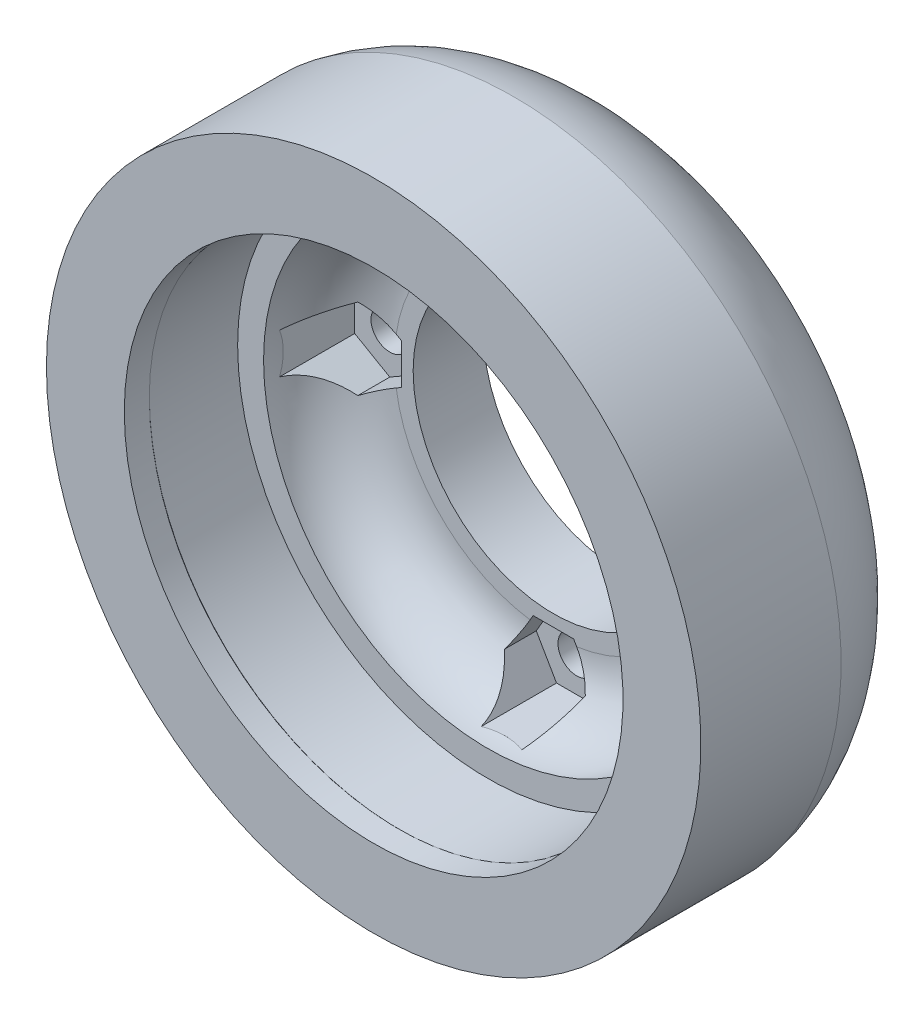
from build123d import *

# Parameters (mm, degrees)
CUT_EXTRUDE1_DEPTH = 12.065
SKETCH4_R          = 2.5527
CUT_EXTRUDE2_DEPTH = 7.35
CIRPATTERN1_COUNT  = 4


with BuildPart() as part:
    # Sketch2 → Revolve1 (revolve)
    with BuildSketch(Plane(origin=(0, 0, 0), x_dir=(0, 0, -1), z_dir=(1, 0, 0))):
        with BuildLine():
            Line((6, 34), (-6, 34))
            Line((-6, 34), (-6.127, 33.873))
            Line((-6.127, 33.873), (-9.525, 33.873))
            Line((-9.525, 33.873), (-9.525, 44.45))
            Line((-9.525, 44.45), (9.525, 44.45))
            ThreePointArc((9.525, 44.45), (18.725516989, 40.158239998), (24.415, 31.75))
            Line((24.415, 31.75), (24.415, 19.05))
            Line((24.415, 19.05), (14.89, 19.05))
            Line((14.89, 19.05), (14.89, 21.59))
            ThreePointArc((14.89, 21.59), (12.286179285, 27.876179285), (6, 30.48))
            Line((6, 30.48), (6, 34))
        make_face()
    revolve(axis=Axis((0, 0, 0), (0, 0, 1)))

    # Sketch3 → Cut-Extrude1 (cut)
    with BuildSketch(Plane.XY.offset(-6)):
        Polygon((5.499261314, 25.4), (2.749630657, 30.1625), (-2.749630657, 30.1625), (-5.499261314, 25.4), (-2.749630657, 20.6375), (2.749630657, 20.6375), align=None)
    cut_extrude1 = extrude(amount=-CUT_EXTRUDE1_DEPTH, mode=Mode.SUBTRACT)

    # Sketch4 → Cut-Extrude2 (cut, through all)
    with BuildSketch(Plane.XY.offset(-18.065)):
        with Locations((0, 25.4)):
            Circle(SKETCH4_R)
    cut_extrude2 = extrude(amount=-CUT_EXTRUDE2_DEPTH, mode=Mode.SUBTRACT)

    # CirPattern1: Cut-Extrude1, Cut-Extrude2 ×4 about axis
    cirpattern1_axis = Axis((0, 0, 0), (0, 0, 1))
    for i in range(1, CIRPATTERN1_COUNT):
        add(cut_extrude1.rotate(cirpattern1_axis, i * 360 / CIRPATTERN1_COUNT), mode=Mode.SUBTRACT)
        add(cut_extrude2.rotate(cirpattern1_axis, i * 360 / CIRPATTERN1_COUNT), mode=Mode.SUBTRACT)


solid = part.part
